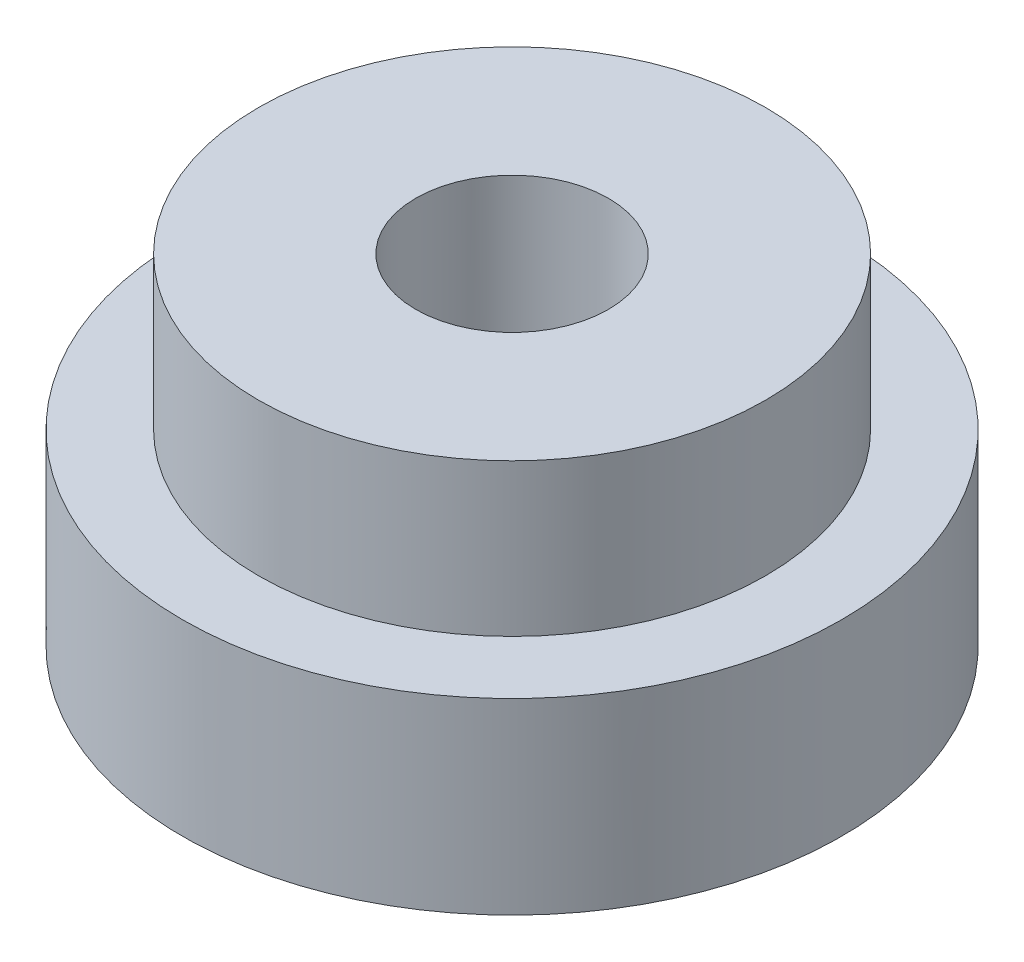
from build123d import *

# Parameters (mm, degrees)
CROQUIS1_R              = 6.5
SALIENTE_EXTRUIR1_DEPTH = 1.2
CROQUIS2_R              = 5
SALIENTE_EXTRUIR2_DEPTH = 3
CROQUIS3_R              = 1.8
CORTAR_EXTRUIR1_DEPTH   = 3
CORTAR_EXTRUIR2_REACH   = 6.2
CROQUIS4_R              = 1.9
CROQUIS5_R              = 6.5
SALIENTE_EXTRUIR3_DEPTH = 2.5
CORTAR_EXTRUIR3_DEPTH   = 2.5


with BuildPart() as part:
    # Croquis1 → Saliente-Extruir1 (new body)
    with BuildSketch(Plane(origin=(0, 0, 0), x_dir=(1, 0, 0), z_dir=(0, 1, 0))):
        Circle(CROQUIS1_R)
    extrude(amount=SALIENTE_EXTRUIR1_DEPTH)

    # Croquis2 → Saliente-Extruir2 (add)
    with BuildSketch(Plane(origin=(0, 1.2, 0), x_dir=(1, 0, 0), z_dir=(0, 1, 0))):
        Circle(CROQUIS2_R)
    extrude(amount=SALIENTE_EXTRUIR2_DEPTH)

    # Croquis3 → Cortar-Extruir1 (cut)
    with BuildSketch(Plane(origin=(0, 4.2, 0), x_dir=(1, 0, 0), z_dir=(0, 1, 0))):
        Circle(CROQUIS3_R)
    extrude(amount=-CORTAR_EXTRUIR1_DEPTH, mode=Mode.SUBTRACT)

    # Croquis4 → Cortar-Extruir2 (cut, up to next)
    with BuildSketch(Plane.XZ, mode=Mode.PRIVATE) as cortar_extruir2_sk1:
        Circle(CROQUIS4_R)
    cortar_extruir2_tool1 = extrude(cortar_extruir2_sk1.sketch, amount=-CORTAR_EXTRUIR2_REACH, mode=Mode.PRIVATE) & part.part
    add(cortar_extruir2_tool1.solids().sort_by_distance((0, 0, 0))[0], mode=Mode.SUBTRACT)

    # Croquis5 → Saliente-Extruir3 (add)
    with BuildSketch(Plane.XZ):
        Circle(CROQUIS5_R)
    extrude(amount=SALIENTE_EXTRUIR3_DEPTH)

    # Croquis6 → Cortar-Extruir3 (cut)
    with BuildSketch(Plane.XZ.offset(2.5)):
        Polygon((-3.300733133, 1.228207686), (-2.714025623, -2.244414901), (0.586707509, -3.472622587), (3.300733133, -1.228207686), (2.714025623, 2.244414901), (-0.586707509, 3.472622587), align=None)
    extrude(amount=-CORTAR_EXTRUIR3_DEPTH, mode=Mode.SUBTRACT)


solid = part.part
